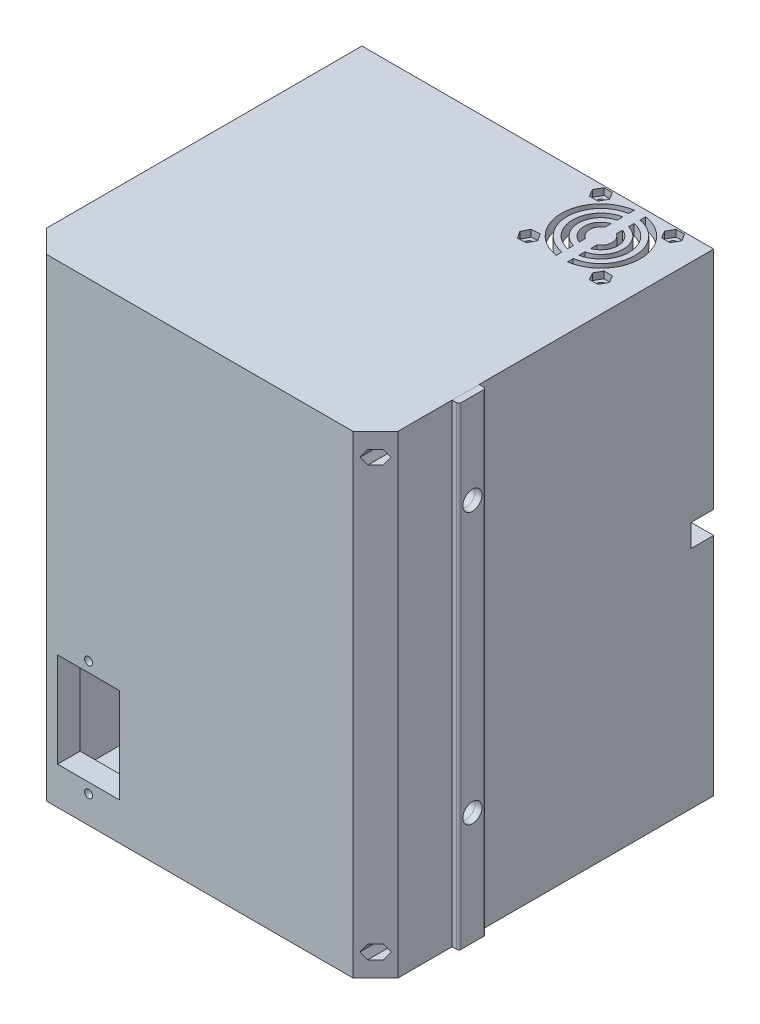
from build123d import *

# Parameters (mm, degrees)
BOSS_EXTRUDE1_DEPTH      = 200
SKETCH2_R                = 1.75
CUT_EXTRUDE1_DEPTH       = 79
BOSS_EXTRUDE2_DEPTH      = 5
SKETCH8_W                = 15
SKETCH8_H                = 13
CUT_EXTRUDE4_DEPTH       = 201
CUT_EXTRUDE4_DEPTH_BACK  = 6
BOSS_EXTRUDE3_START      = 200
BOSS_EXTRUDE3_DEPTH      = 5
SKETCH9_R                = 1.75
SKETCH9_W                = 27.5
SKETCH9_H                = 42
CUT_EXTRUDE5_DEPTH       = 1
CUT_EXTRUDE5_DEPTH_BACK  = 151
SKETCH13_R               = 1.75
CUT_EXTRUDE7_DEPTH       = 206
SKETCH16_R               = 17.5
CUT_EXTRUDE8_DEPTH       = 206
BOSS_EXTRUDE4_START      = 200
SKETCH17_R               = 15
SKETCH17_R_2             = 12.5
BOSS_EXTRUDE4_DEPTH      = 5
BOSS_EXTRUDE5_START      = 200
SKETCH18_R               = 10
SKETCH18_R_2             = 7.5
BOSS_EXTRUDE5_DEPTH      = 5
BOSS_EXTRUDE6_START      = 200
SKETCH19_R               = 5
SKETCH19_R_2             = 2.5
BOSS_EXTRUDE6_DEPTH      = 5
BOSS_EXTRUDE7_START      = 200
SKETCH20_R               = 1.5
BOSS_EXTRUDE7_DEPTH      = 5
SKETCH23_W               = 12
SKETCH23_H               = 210
BOSS_EXTRUDE9_DEPTH      = 3
CUT_EXTRUDE10_START      = 78
SKETCH22_R               = 4.25
CUT_EXTRUDE10_DEPTH      = 3
FILLET1_R                = 1
BOSS_EXTRUDE10_DEPTH     = 20
CUT_EXTRUDE11_START      = -10
SKETCH27_R               = 1.5
CUT_EXTRUDE11_DEPTH      = 141
CUT_EXTRUDE12_START      = -10
CUT_EXTRUDE12_DEPTH      = 70
BOSS_EXTRUDE11_START     = 192
BOSS_EXTRUDE11_DEPTH     = 20
CUT_EXTRUDE14_START      = -10
SKETCH30_R               = 1.75
CUT_EXTRUDE14_DEPTH      = 141
CUT_EXTRUDE15_START      = -10
CUT_EXTRUDE15_DEPTH      = 70
BOSS_EXTRUDE12_START     = 200
SKETCH34_W               = 5
SKETCH34_H               = 37.357004132
BOSS_EXTRUDE12_DEPTH     = 5
SKETCH37_R               = 4.25
CUT_EXTRUDE16_DEPTH      = 81
CUT_EXTRUDE17_START      = -13
SKETCH39_R               = 8
CUT_EXTRUDE17_DEPTH      = 7
CUT_EXTRUDE18_DEPTH      = 125
SKETCH43_R               = 1.75
CUT_EXTRUDE19_DEPTH      = 1
CUT_EXTRUDE19_DEPTH_BACK = 151
CUT_EXTRUDE20_START      = -150
SKETCH44_W               = 162
SKETCH44_H               = 10
CUT_EXTRUDE20_DEPTH      = 10
CUT_EXTRUDE21_START      = -78
SKETCH45_R               = 3.5
CUT_EXTRUDE21_DEPTH      = 3
CUT_EXTRUDE22_DEPTH      = 3


with BuildPart() as part:
    # Sketch1 → Boss-Extrude1 (new body)
    with BuildSketch(Plane(origin=(0, 0, 0), x_dir=(1, 0, 0), z_dir=(0, 1, 0))):
        Polygon((0, 0), (68, 0), (78, 10), (78, 150), (68, 150), (68, 10), (0, 10), align=None)
    boss_extrude1 = extrude(amount=BOSS_EXTRUDE1_DEPTH)

    # Mirror1: Boss-Extrude1 across plane
    add(boss_extrude1.mirror(Plane(origin=(0, 0, 0), x_dir=(0, 0, 1), z_dir=(1, 0, 0))))

    # Sketch2 → Cut-Extrude1 (cut, through all)
    with BuildSketch(Plane(origin=(0, 0, 0), x_dir=(0, 0, -1), z_dir=(1, 0, 0))):
        with Locations((29.5, 103)):
            Circle(SKETCH2_R)
        with Locations((38.5, 180)):
            Circle(SKETCH2_R)
        with Locations((20.5, 180)):
            Circle(SKETCH2_R)
    extrude(amount=-CUT_EXTRUDE1_DEPTH, mode=Mode.SUBTRACT)

    # Sketch6 → Boss-Extrude2 (add)
    with BuildSketch(Plane(origin=(0, 0, 0), x_dir=(1, 0, 0), z_dir=(0, 1, 0))):
        Polygon((78, 150), (-78, 150), (-78, 10), (-68, 0), (68, 0), (78, 10), align=None)
    extrude(amount=-BOSS_EXTRUDE2_DEPTH)

    # Sketch8 → Cut-Extrude4 (cut, two sides)
    with BuildSketch(Plane(origin=(0, 0, 0), x_dir=(1, 0, 0), z_dir=(0, 1, 0))) as cut_extrude4_sk:
        with Locations((45, 97.7)):
            Rectangle(SKETCH8_W, SKETCH8_H)
    extrude(amount=CUT_EXTRUDE4_DEPTH, mode=Mode.SUBTRACT)
    extrude(cut_extrude4_sk.sketch, amount=-CUT_EXTRUDE4_DEPTH_BACK, mode=Mode.SUBTRACT)

    # Sketch6_2 → Boss-Extrude3 (add)
    with BuildSketch(Plane(origin=(0, 0, 0), x_dir=(1, 0, 0), z_dir=(0, 1, 0)).offset(BOSS_EXTRUDE3_START)):
        Polygon((78, 150), (-78, 150), (-78, 10), (-68, 0), (68, 0), (78, 10), align=None)
    extrude(amount=BOSS_EXTRUDE3_DEPTH)

    # Sketch9 → Cut-Extrude5 (cut, two sides)
    with BuildSketch(Plane.XY) as cut_extrude5_sk:
        with Locations((-49.25, 7.12638739)):
            Circle(SKETCH9_R)
        with Locations((-49.25, 58.12638739)):
            Circle(SKETCH9_R)
        with Locations((-49.25, 32.62638739)):
            Rectangle(SKETCH9_W, SKETCH9_H)
    extrude(amount=CUT_EXTRUDE5_DEPTH, mode=Mode.SUBTRACT)
    extrude(cut_extrude5_sk.sketch, amount=-CUT_EXTRUDE5_DEPTH_BACK, mode=Mode.SUBTRACT)

    # Sketch13 → Cut-Extrude7 (cut, through all)
    with BuildSketch(Plane(origin=(0, 0, 0), x_dir=(1, 0, 0), z_dir=(0, 1, 0))):
        with Locations((64, 114)):
            Circle(SKETCH13_R)
        with Locations((32, 114)):
            Circle(SKETCH13_R)
        with Locations((32, 146)):
            Circle(SKETCH13_R)
        with Locations((64, 146)):
            Circle(SKETCH13_R)
    extrude(amount=CUT_EXTRUDE7_DEPTH, mode=Mode.SUBTRACT)

    # Sketch16 → Cut-Extrude8 (cut, through all)
    with BuildSketch(Plane(origin=(0, 0, 0), x_dir=(1, 0, 0), z_dir=(0, 1, 0))):
        with Locations((48, 130)):
            Circle(SKETCH16_R)
    extrude(amount=CUT_EXTRUDE8_DEPTH, mode=Mode.SUBTRACT)

    # Sketch25 → Boss-Extrude10 (add)
    with BuildSketch(Plane(origin=(0, 0, 0), x_dir=(1, 0, 0), z_dir=(0, 1, 0))):
        Polygon((-68, 50), (-48, 84.641016151), (-68, 84.641016151), align=None)
    boss_extrude10 = extrude(amount=BOSS_EXTRUDE10_DEPTH)

    # Sketch27 → Cut-Extrude11 (cut, through all)
    with BuildSketch(Plane.XY.offset(CUT_EXTRUDE11_START)):
        with Locations((-58, 10)):
            Circle(SKETCH27_R)
    cut_extrude11 = extrude(amount=-CUT_EXTRUDE11_DEPTH, mode=Mode.SUBTRACT)

    # Sketch28 → Cut-Extrude12 (cut)
    with BuildSketch(Plane.XY.offset(CUT_EXTRUDE12_START)):
        Polygon((-54.535898385, 9.999998876), (-56.267948219, 12.999999438), (-59.732049834, 13.000000562), (-61.464101615, 10.000001124), (-59.732051781, 7.000000562), (-56.267950166, 6.999999438), align=None)
    cut_extrude12 = extrude(amount=-CUT_EXTRUDE12_DEPTH, mode=Mode.SUBTRACT)

    # Mirror2: Boss-Extrude10, Cut-Extrude11, Cut-Extrude12 across plane
    add(boss_extrude10.mirror(Plane.ZY))
    add(cut_extrude11.mirror(Plane.ZY), mode=Mode.SUBTRACT)
    add(cut_extrude12.mirror(Plane.ZY), mode=Mode.SUBTRACT)

    # Sketch25_2 → Boss-Extrude11 (add)
    with BuildSketch(Plane(origin=(0, 0, 0), x_dir=(1, 0, 0), z_dir=(0, 1, 0)).offset(BOSS_EXTRUDE11_START)):
        Polygon((-68, 50), (-48, 84.641016151), (-68, 84.641016151), align=None)
    boss_extrude11 = extrude(amount=-BOSS_EXTRUDE11_DEPTH)

    # Sketch30 → Cut-Extrude14 (cut, through all)
    with BuildSketch(Plane.XY.offset(CUT_EXTRUDE14_START)):
        with Locations((-58, 182)):
            Circle(SKETCH30_R)
    cut_extrude14 = extrude(amount=-CUT_EXTRUDE14_DEPTH, mode=Mode.SUBTRACT)

    # Sketch31 → Cut-Extrude15 (cut)
    with BuildSketch(Plane.XY.offset(CUT_EXTRUDE15_START)):
        Polygon((-54.535898385, 182), (-56.267949192, 185), (-59.732050807, 185), (-61.464101615, 182), (-59.732050807, 179), (-56.267949192, 179), align=None)
    cut_extrude15 = extrude(amount=-CUT_EXTRUDE15_DEPTH, mode=Mode.SUBTRACT)

    # Mirror6: Boss-Extrude11, Cut-Extrude14, Cut-Extrude15 across plane
    add(boss_extrude11.mirror(Plane.ZY))
    add(cut_extrude14.mirror(Plane.ZY), mode=Mode.SUBTRACT)
    add(cut_extrude15.mirror(Plane.ZY), mode=Mode.SUBTRACT)



with BuildPart() as body_2:
    # Sketch17 → Boss-Extrude4 (new body, through all)
    with BuildSketch(Plane(origin=(0, 0, 0), x_dir=(1, 0, 0), z_dir=(0, 1, 0)).offset(BOSS_EXTRUDE4_START)):
        with Locations((48, 130)):
            Circle(SKETCH17_R)
        with Locations((48, 130)):
            Circle(SKETCH17_R_2, mode=Mode.SUBTRACT)
    extrude(amount=BOSS_EXTRUDE4_DEPTH)


with BuildPart() as body_3:
    # Sketch18 → Boss-Extrude5 (new body)
    with BuildSketch(Plane(origin=(0, 0, 0), x_dir=(1, 0, 0), z_dir=(0, 1, 0)).offset(BOSS_EXTRUDE5_START)):
        with Locations((48, 130)):
            Circle(SKETCH18_R)
        with Locations((48, 130)):
            Circle(SKETCH18_R_2, mode=Mode.SUBTRACT)
    extrude(amount=BOSS_EXTRUDE5_DEPTH)


with BuildPart() as body_4:
    # Sketch19 → Boss-Extrude6 (new body)
    with BuildSketch(Plane(origin=(0, 0, 0), x_dir=(1, 0, 0), z_dir=(0, 1, 0)).offset(BOSS_EXTRUDE6_START)):
        with Locations((48, 130)):
            Circle(SKETCH19_R)
        with Locations((48, 130)):
            Circle(SKETCH19_R_2, mode=Mode.SUBTRACT)
    extrude(amount=BOSS_EXTRUDE6_DEPTH)


with BuildPart() as body_5:
    # Sketch20 → Boss-Extrude7 (new body)
    with BuildSketch(Plane(origin=(0, 0, 0), x_dir=(1, 0, 0), z_dir=(0, 1, 0)).offset(BOSS_EXTRUDE7_START)):
        with Locations((48, 130)):
            Circle(SKETCH20_R)
    extrude(amount=BOSS_EXTRUDE7_DEPTH)


with BuildPart() as body_6:
    # Sketch23 → Boss-Extrude9 (new body)
    with BuildSketch(Plane(origin=(78, 0, 0), x_dir=(0, 0, -1), z_dir=(1, 0, 0))):
        with Locations((40, 100)):
            Rectangle(SKETCH23_W, SKETCH23_H)
    extrude(amount=BOSS_EXTRUDE9_DEPTH)

    # Sketch22 → Cut-Extrude10 (cut)
    with BuildSketch(Plane(origin=(0, 0, 0), x_dir=(0, 0, -1), z_dir=(1, 0, 0)).offset(CUT_EXTRUDE10_START)):
        with Locations((40, 165)):
            Circle(SKETCH22_R)
        with Locations((40, 45)):
            Circle(SKETCH22_R)
    extrude(amount=CUT_EXTRUDE10_DEPTH, mode=Mode.SUBTRACT)

    # Fillet1
    fillet1_edges = [body_6.edges().sort_by_distance(p)[0] for p in [
        (81, 100, -34),
        (81, 100, -46),
    ]]
    fillet(fillet1_edges, radius=FILLET1_R)


with BuildPart() as part_1:
    add(part.part)

    add(body_2.part)  # Boss-Extrude12 merges body 2

    add(body_3.part)  # Boss-Extrude12 merges body 3

    add(body_4.part)  # Boss-Extrude12 merges body 4

    add(body_5.part)  # Boss-Extrude12 merges body 5
    # Sketch34 → Boss-Extrude12 (add)
    with BuildSketch(Plane(origin=(0, 0, 0), x_dir=(1, 0, 0), z_dir=(0, 1, 0)).offset(BOSS_EXTRUDE12_START)):
        with Locations((48, 130)):
            Rectangle(SKETCH34_W, SKETCH34_H)
    extrude(amount=BOSS_EXTRUDE12_DEPTH)

    # Sketch37 → Cut-Extrude16 (cut)
    with BuildSketch(Plane(origin=(0, 0, 0), x_dir=(0, 0, -1), z_dir=(1, 0, 0))):
        with Locations((40, 45)):
            Circle(SKETCH37_R)
        with Locations((40, 165)):
            Circle(SKETCH37_R)
    extrude(amount=CUT_EXTRUDE16_DEPTH, mode=Mode.SUBTRACT)

    # Sketch39 → Cut-Extrude17 (cut)
    with BuildSketch(Plane(origin=(81, 0, 0), x_dir=(0, 0, -1), z_dir=(1, 0, 0)).offset(CUT_EXTRUDE17_START)):
        with Locations((40, 165)):
            Circle(SKETCH39_R)
        with Locations((40, 45)):
            Circle(SKETCH39_R)
    extrude(amount=CUT_EXTRUDE17_DEPTH, mode=Mode.SUBTRACT)

    # Sketch40 → Cut-Extrude18 (cut)
    with BuildSketch(Plane.XY):
        Polygon((-76.464101615, 5), (-74.732050808, 2), (-71.267949192, 2), (-69.535898385, 5), (-71.267949192, 8), (-74.732050808, 8), align=None)
        Polygon((76.464101615, 5), (74.732050808, 8), (71.267949192, 8), (69.535898385, 5), (71.267949192, 2), (74.732050808, 2), align=None)
        Polygon((69.535898385, 195), (71.267949192, 192), (74.732050808, 192), (76.464101615, 195), (74.732050808, 198), (71.267949192, 198), align=None)
        Polygon((-76.464101615, 195), (-74.732050808, 192), (-71.267949192, 192), (-69.535898385, 195), (-71.267949192, 198), (-74.732050808, 198), align=None)
    extrude(amount=-CUT_EXTRUDE18_DEPTH, mode=Mode.SUBTRACT)

    # Sketch43 → Cut-Extrude19 (cut, two sides)
    with BuildSketch(Plane.XY) as cut_extrude19_sk:
        with Locations((73, 195)):
            Circle(SKETCH43_R)
        with Locations((-73, 195)):
            Circle(SKETCH43_R)
        with Locations((-73, 5)):
            Circle(SKETCH43_R)
        with Locations((73, 5)):
            Circle(SKETCH43_R)
    extrude(amount=CUT_EXTRUDE19_DEPTH, mode=Mode.SUBTRACT)
    extrude(cut_extrude19_sk.sketch, amount=-CUT_EXTRUDE19_DEPTH_BACK, mode=Mode.SUBTRACT)

    # Sketch44 → Cut-Extrude20 (cut)
    with BuildSketch(Plane.XY.offset(CUT_EXTRUDE20_START)):
        with Locations((0, 100)):
            Rectangle(SKETCH44_W, SKETCH44_H)
    extrude(amount=CUT_EXTRUDE20_DEPTH, mode=Mode.SUBTRACT)

    # Sketch45 → Cut-Extrude21 (cut)
    with BuildSketch(Plane(origin=(0, 0, 0), x_dir=(0, 0, -1), z_dir=(1, 0, 0)).offset(CUT_EXTRUDE21_START)):
        with Locations((29.5, 103)):
            Circle(SKETCH45_R)
        with Locations((38.5, 180)):
            Circle(SKETCH45_R)
        with Locations((20.5, 180)):
            Circle(SKETCH45_R)
    extrude(amount=CUT_EXTRUDE21_DEPTH, mode=Mode.SUBTRACT)

    # Sketch46 → Cut-Extrude22 (cut)
    with BuildSketch(Plane(origin=(0, 205, 0), x_dir=(1, 0, 0), z_dir=(0, 1, 0))):
        Polygon((60.24722325, 114), (62.123611625, 110.75), (65.876388375, 110.75), (67.75277675, 114), (65.876388375, 117.25), (62.123611625, 117.25), align=None)
        Polygon((28.254747632, 113.76247519), (30.333076336, 110.637753901), (34.078328703, 110.875278711), (35.745252368, 114.23752481), (33.666923664, 117.362246099), (29.921671297, 117.124721289), align=None)
        Polygon((28.24722325, 146), (30.123611625, 142.75), (33.876388375, 142.75), (35.75277675, 146), (33.876388375, 149.25), (30.123611625, 149.25), align=None)
        Polygon((60.24722325, 146), (62.123611625, 142.75), (65.876388375, 142.75), (67.75277675, 146), (65.876388375, 149.25), (62.123611625, 149.25), align=None)
    extrude(amount=-CUT_EXTRUDE22_DEPTH, mode=Mode.SUBTRACT)


solid = Compound([body_6.part, part_1.part])
